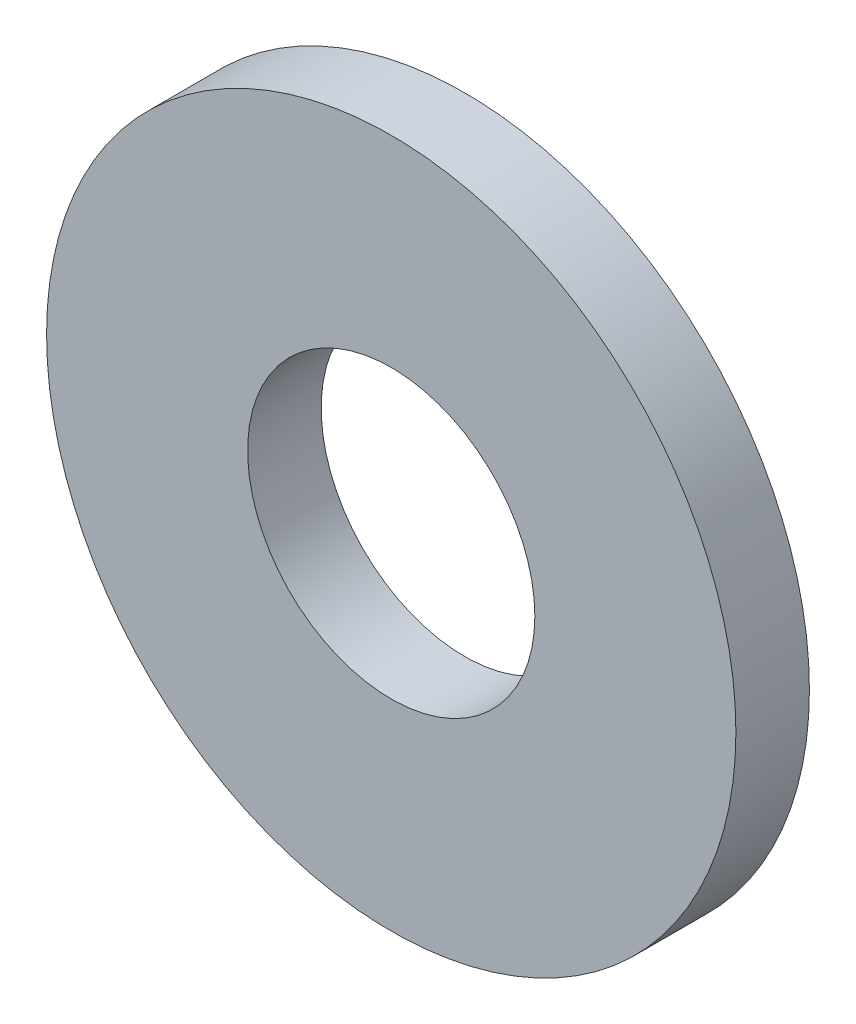
from build123d import *

# Parameters (mm, degrees)
SKETCH1_R      = 9.525
SKETCH1_R_2    = 3.96875
EXTRUDE1_DEPTH = 2.032


with BuildPart() as part:
    # Sketch1 → Extrude1 (new body)
    with BuildSketch(Plane.XY):
        Circle(SKETCH1_R)
        Circle(SKETCH1_R_2, mode=Mode.SUBTRACT)
    extrude(amount=-EXTRUDE1_DEPTH)


solid = part.part
